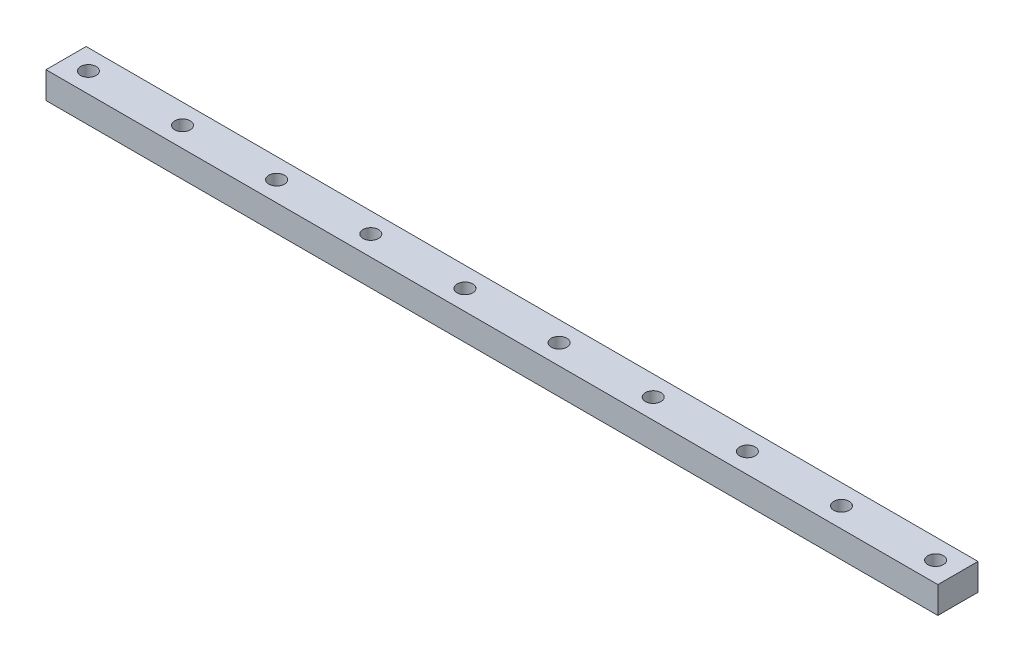
from build123d import *

# Parameters (mm, degrees)
SKETCH1_W           = 200
SKETCH1_H           = 9
BOSS_EXTRUDE1_DEPTH = 6
SKETCH2_R           = 1.75
CUT_EXTRUDE1_DEPTH  = 6
LPATTERN1_COUNT     = 10
LPATTERN1_PITCH     = 21.111111111


with BuildPart() as part:
    # Sketch1 → Boss-Extrude1 (new body)
    with BuildSketch(Plane(origin=(0, 0, 0), x_dir=(1, 0, 0), z_dir=(0, 1, 0))):
        with Locations((100, 4.5)):
            Rectangle(SKETCH1_W, SKETCH1_H)
    extrude(amount=BOSS_EXTRUDE1_DEPTH)

    # Sketch2 → Cut-Extrude1 (cut)
    with BuildSketch(Plane(origin=(0, 6, 0), x_dir=(1, 0, 0), z_dir=(0, 1, 0))):
        with Locations((5, 4.5)):
            Circle(SKETCH2_R)
    cut_extrude1 = extrude(amount=-CUT_EXTRUDE1_DEPTH, mode=Mode.SUBTRACT)

    # LPattern1: Cut-Extrude1 ×10
    with Locations(*[(i * LPATTERN1_PITCH, 0, 0) for i in range(1, LPATTERN1_COUNT)]):
        add(cut_extrude1, mode=Mode.SUBTRACT)


solid = part.part
